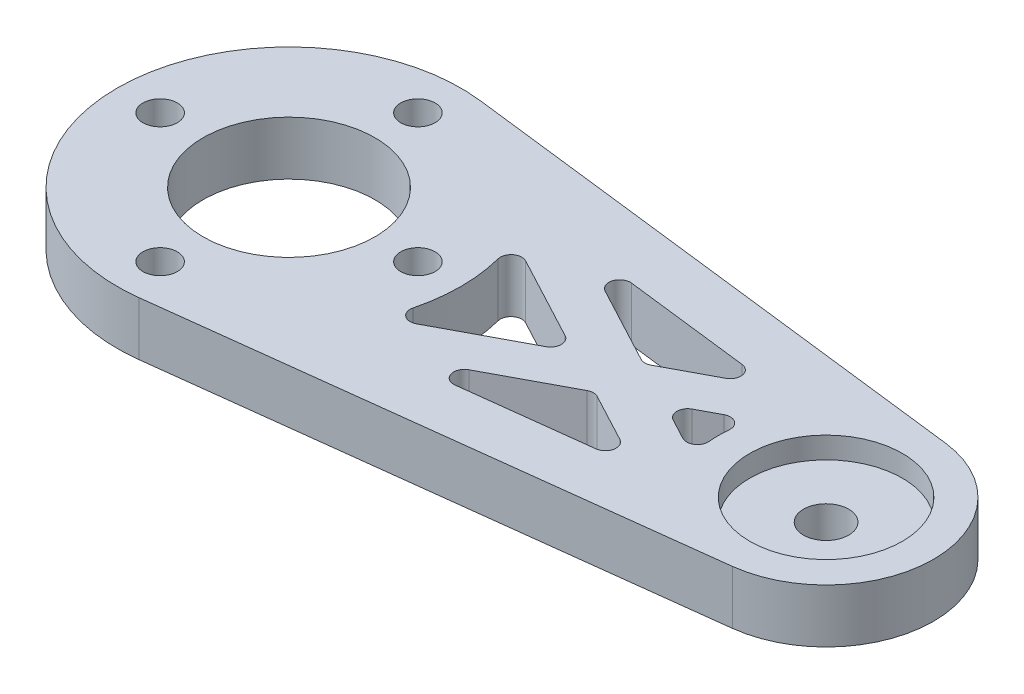
from build123d import *

# Parameters (mm, degrees)
SKETCH_1_R      = 1.6
SKETCH_1_R_2    = 8
SKETCH_1_R_3    = 7.1
EXTRUDE_1_DEPTH = 5
SKETCH_1_3_R    = 7.1
SKETCH_1_3_R_2  = 2.1
EXTRUDE_2_DEPTH = 3
FILLET_1_R      = 1
FILLET_2_R      = 1
FILLET_3_R      = 1
FILLET_4_R      = 1


with BuildPart() as part:
    # 草图1 → 凸台-拉伸1 (new body)
    with BuildSketch(Plane(origin=(0, 0, 0), x_dir=(1, 0, 0), z_dir=(0, 1, 0))):
        with BuildLine():
            ThreePointArc((1.92, 15.884382267), (-16, 0), (1.92, -15.884382267))
            Line((1.92, -15.884382267), (51.2, -9.927738917))
            ThreePointArc((51.2, -9.927738917), (60, 0), (51.2, 9.927738917))
            Line((51.2, 9.927738917), (1.92, 15.884382267))
        make_face()
        with Locations((0, -12)):
            Circle(SKETCH_1_R, mode=Mode.SUBTRACT)
        with Locations((-12, 0)):
            Circle(SKETCH_1_R, mode=Mode.SUBTRACT)
        Circle(SKETCH_1_R_2, mode=Mode.SUBTRACT)
        with Locations((12, 0)):
            Circle(SKETCH_1_R, mode=Mode.SUBTRACT)
        Polygon((38.535462938, -6.422151611), (18.356508588, -8.861251331), (30.734984007, -2.266153232), align=None, mode=Mode.SUBTRACT)
        with BuildLine():
            Line((40.429404433, -2.898913674), (34.988373668, 0))
            Line((34.988373668, 0), (40.429404433, 2.898913674))
            ThreePointArc((40.429404433, 2.898913674), (40, 0), (40.429404433, -2.898913674))
        make_face(mode=Mode.SUBTRACT)
        with Locations((50, 0)):
            Circle(SKETCH_1_R_3, mode=Mode.SUBTRACT)
        with BuildLine():
            ThreePointArc((14.72234722, -6.265180949), (16, 0), (14.72234722, 6.265180949))
            Line((14.72234722, 6.265180949), (26.481594346, 0))
            Line((26.481594346, 0), (14.72234722, -6.265180949))
        make_face(mode=Mode.SUBTRACT)
        with Locations((0, 12)):
            Circle(SKETCH_1_R, mode=Mode.SUBTRACT)
        Polygon((30.734984007, 2.266153232), (18.356508588, 8.861251331), (38.535462938, 6.422151611), align=None, mode=Mode.SUBTRACT)
    extrude(amount=EXTRUDE_1_DEPTH)

    # 草图1<3> → 凸台-拉伸2 (add)
    with BuildSketch(Plane(origin=(0, 0, 0), x_dir=(1, 0, 0), z_dir=(0, 1, 0))):
        with Locations((50, 0)):
            Circle(SKETCH_1_3_R)
        with Locations((50, 0)):
            Circle(SKETCH_1_3_R_2, mode=Mode.SUBTRACT)
    extrude(amount=EXTRUDE_2_DEPTH)

    # 圆角1
    fillet_1_edges = [part.edges().sort_by_distance(p)[0] for p in [
        (34.988373668, 2.5, 0),
        (40.429404433, 2.5, -2.898913674),
        (40.429404433, 2.5, 2.898913674),
    ]]
    fillet(fillet_1_edges, radius=FILLET_1_R)

    # 圆角2
    fillet_2_edges = [part.edges().sort_by_distance(p)[0] for p in [
        (30.734984007, 2.5, 2.266153232),
        (18.356508588, 2.5, 8.861251331),
        (38.535462938, 2.5, 6.422151611),
    ]]
    fillet(fillet_2_edges, radius=FILLET_2_R)

    # 圆角3
    fillet_3_edges = [part.edges().sort_by_distance(p)[0] for p in [
        (18.356508588, 2.5, -8.861251331),
        (30.734984007, 2.5, -2.266153232),
        (38.535462938, 2.5, -6.422151611),
    ]]
    fillet(fillet_3_edges, radius=FILLET_3_R)

    # 圆角4
    fillet_4_edges = [part.edges().sort_by_distance(p)[0] for p in [
        (14.72234722, 2.5, -6.265180949),
        (26.481594346, 2.5, 0),
        (14.72234722, 2.5, 6.265180949),
    ]]
    fillet(fillet_4_edges, radius=FILLET_4_R)


solid = part.part
